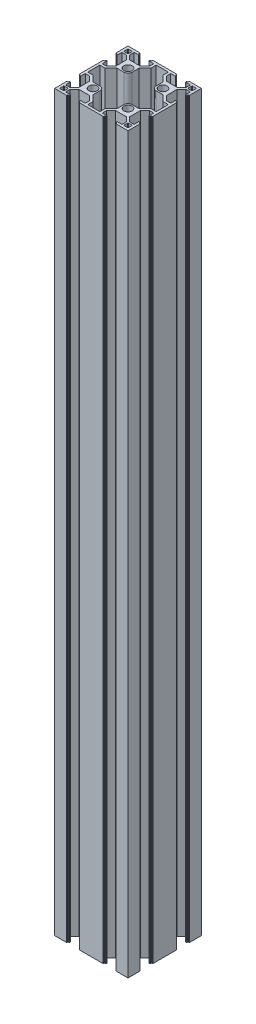
from build123d import *

# Parameters (mm, degrees)
SKETCH1_W                = 60
SKETCH1_H                = 60
BOSS_EXTRUDE1_DEPTH      = 600
CUT_EXTRUDE1_DEPTH       = 602.498129673
CIRPATTERN1_COUNT        = 4
CIRPATTERN1_COPY_1_DEPTH = 602.498129673
CIRPATTERN1_COPY_2_DEPTH = 602.498129673
CIRPATTERN1_COPY_3_DEPTH = 602.498129673
SKETCH4_R                = 3.4
CUT_EXTRUDE2_DEPTH       = 602.498129673
FILLET1_R                = 0.2
FILLET2_R                = 0.2
FILLET3_R                = 0.2
FILLET4_R                = 0.2


with BuildPart() as part:
    # Sketch1 → Boss-Extrude1 (new body)
    with BuildSketch(Plane(origin=(0, 0, 0), x_dir=(1, 0, 0), z_dir=(0, 1, 0))):
        Rectangle(SKETCH1_W, SKETCH1_H)
        Polygon((-23.05, -28), (-6.95, -28), (-6.95, -24.4), (-10.615, -20.8), (-19.385, -20.8), (-23.05, -24.4), align=None, mode=Mode.SUBTRACT)
        Polygon((10.615, -20.8), (19.385, -20.8), (23.05, -24.4), (23.05, -28), (6.95, -28), (6.95, -24.4), align=None, mode=Mode.SUBTRACT)
        Polygon((19.385, 20.8), (23.05, 24.4), (23.05, 28), (6.95, 28), (6.95, 24.4), (10.615, 20.8), align=None, mode=Mode.SUBTRACT)
        Polygon((-23.05, 24.4), (-23.05, 28), (-6.95, 28), (-6.95, 24.4), (-10.615, 20.8), (-19.385, 20.8), align=None, mode=Mode.SUBTRACT)
        Polygon((-20.8, 19.385), (-24.4, 23.05), (-28, 23.05), (-28, 6.95), (-24.4, 6.95), (-20.8, 10.615), align=None, mode=Mode.SUBTRACT)
        Polygon((-24.4, -23.05), (-28, -23.05), (-28, -6.95), (-24.4, -6.95), (-20.8, -10.615), (-20.8, -19.385), align=None, mode=Mode.SUBTRACT)
        Polygon((20.8, -19.385), (24.4, -23.05), (28, -23.05), (28, -6.95), (24.4, -6.95), (20.8, -10.615), align=None, mode=Mode.SUBTRACT)
        Polygon((24.4, 23.05), (28, 23.05), (28, 6.95), (24.4, 6.95), (20.8, 10.615), (20.8, 19.385), align=None, mode=Mode.SUBTRACT)
    extrude(amount=BOSS_EXTRUDE1_DEPTH)

    # Sketch2 → Cut-Extrude1 (cut, through all)
    with BuildSketch(Plane(origin=(0, 600, 0), x_dir=(1, 0, 0), z_dir=(0, 1, 0))):
        Polygon((-19.1, -28), (-19.1, -29), (-20.1, -29), (-20.1, -30), (-9.9, -30), (-9.9, -29), (-10.9, -29), (-10.9, -28), align=None)
    cut_extrude1 = extrude(amount=-CUT_EXTRUDE1_DEPTH, mode=Mode.SUBTRACT)

    # Mirror1: Cut-Extrude1 across plane
    add(cut_extrude1.mirror(Plane(origin=(0, 0, 0), x_dir=(0, 0, 1), z_dir=(1, 0, 0))), mode=Mode.SUBTRACT)

    # CirPattern1: Cut-Extrude1 ×4 about axis
    cirpattern1_axis = Axis((0, 1050, 0), (0, -1, 0))
    for i in range(1, CIRPATTERN1_COUNT):
        add(cut_extrude1.rotate(cirpattern1_axis, i * 360 / CIRPATTERN1_COUNT), mode=Mode.SUBTRACT)

    # CirPattern1 copy 1 sketch → CirPattern1 copy 1 (cut, through all)
    with BuildSketch(Plane(origin=(0, 600, 0), x_dir=(0, 0, -1), z_dir=(0, 1, 0))):
        Polygon((-19.1, 28), (-19.1, 29), (-20.1, 29), (-20.1, 30), (-9.9, 30), (-9.9, 29), (-10.9, 29), (-10.9, 28), align=None)
    extrude(amount=-CIRPATTERN1_COPY_1_DEPTH, mode=Mode.SUBTRACT)

    # CirPattern1 copy 2 sketch → CirPattern1 copy 2 (cut, through all)
    with BuildSketch(Plane(origin=(0, 600, 0), x_dir=(1, 0, 0), z_dir=(0, 1, 0))):
        Polygon((-19.1, 28), (-19.1, 29), (-20.1, 29), (-20.1, 30), (-9.9, 30), (-9.9, 29), (-10.9, 29), (-10.9, 28), align=None)
    extrude(amount=-CIRPATTERN1_COPY_2_DEPTH, mode=Mode.SUBTRACT)

    # CirPattern1 copy 3 sketch → CirPattern1 copy 3 (cut, through all)
    with BuildSketch(Plane.ZX.offset(600)):
        Polygon((-19.1, 28), (-19.1, 29), (-20.1, 29), (-20.1, 30), (-9.9, 30), (-9.9, 29), (-10.9, 29), (-10.9, 28), align=None)
    extrude(amount=-CIRPATTERN1_COPY_3_DEPTH, mode=Mode.SUBTRACT)

    # Sketch4 → Cut-Extrude2 (cut, through all)
    with BuildSketch(Plane(origin=(0, 600, 0), x_dir=(1, 0, 0), z_dir=(0, 1, 0))):
        with BuildLine():
            Line((-13.197035349, 9.797035349), (-18.8, 9.797035349))
            Line((-18.8, 9.797035349), (-23.561071557, 4.95))
            Line((-23.561071557, 4.95), (-28, 4.95))
            Line((-28, 4.95), (-28, -4.95))
            Line((-28, -4.95), (-23.561071557, -4.95))
            Line((-23.561071557, -4.95), (-18.8, -9.797035349))
            Line((-18.8, -9.797035349), (-13.197035349, -9.797035349))
            ThreePointArc((-13.197035349, -9.797035349), (-10.792872293, -10.792872293), (-9.797035349, -13.197035349))
            Line((-9.797035349, -13.197035349), (-9.797035349, -18.8))
            Line((-9.797035349, -18.8), (-4.95, -23.561071557))
            Line((-4.95, -23.561071557), (-4.95, -28))
            Line((-4.95, -28), (4.95, -28))
            Line((4.95, -28), (4.95, -23.561071557))
            Line((4.95, -23.561071557), (9.797035349, -18.8))
            Line((9.797035349, -18.8), (9.797035349, -13.197035349))
            ThreePointArc((9.797035349, -13.197035349), (10.792872293, -10.792872293), (13.197035349, -9.797035349))
            Line((13.197035349, -9.797035349), (18.8, -9.797035349))
            Line((18.8, -9.797035349), (23.561071557, -4.95))
            Line((23.561071557, -4.95), (28, -4.95))
            Line((28, -4.95), (28, 4.95))
            Line((28, 4.95), (23.561071557, 4.95))
            Line((23.561071557, 4.95), (18.8, 9.797035349))
            Line((18.8, 9.797035349), (13.197035349, 9.797035349))
            ThreePointArc((13.197035349, 9.797035349), (10.792872293, 10.792872293), (9.797035349, 13.197035349))
            Line((9.797035349, 13.197035349), (9.797035349, 18.8))
            Line((9.797035349, 18.8), (4.95, 23.561071557))
            Line((4.95, 23.561071557), (4.95, 28))
            Line((4.95, 28), (-4.95, 28))
            Line((-4.95, 28), (-4.95, 23.561071557))
            Line((-4.95, 23.561071557), (-9.797035349, 18.8))
            Line((-9.797035349, 18.8), (-9.797035349, 13.197035349))
            ThreePointArc((-9.797035349, 13.197035349), (-10.792872293, 10.792872293), (-13.197035349, 9.797035349))
        make_face()
        with BuildLine():
            ThreePointArc((-28, -27.5), (-27.853553391, -27.853553391), (-27.5, -28))
            Line((-27.5, -28), (-24.9, -28))
            ThreePointArc((-24.9, -28), (-24.546446609, -27.853553391), (-24.4, -27.5))
            Line((-24.4, -27.5), (-24.4, -24.9))
            ThreePointArc((-24.4, -24.9), (-24.546446609, -24.546446609), (-24.9, -24.4))
            Line((-24.9, -24.4), (-27.5, -24.4))
            ThreePointArc((-27.5, -24.4), (-27.853553391, -24.546446609), (-28, -24.9))
            Line((-28, -24.9), (-28, -27.5))
        make_face()
        with BuildLine():
            ThreePointArc((24.4, -27.5), (24.546446609, -27.853553391), (24.9, -28))
            Line((24.9, -28), (27.5, -28))
            ThreePointArc((27.5, -28), (27.853553391, -27.853553391), (28, -27.5))
            Line((28, -27.5), (28, -24.9))
            ThreePointArc((28, -24.9), (27.853553391, -24.546446609), (27.5, -24.4))
            Line((27.5, -24.4), (24.9, -24.4))
            ThreePointArc((24.9, -24.4), (24.546446609, -24.546446609), (24.4, -24.9))
            Line((24.4, -24.9), (24.4, -27.5))
        make_face()
        with BuildLine():
            ThreePointArc((-27.5, 28), (-27.853553391, 27.853553391), (-28, 27.5))
            Line((-28, 27.5), (-28, 24.9))
            ThreePointArc((-28, 24.9), (-27.853553391, 24.546446609), (-27.5, 24.4))
            Line((-27.5, 24.4), (-24.9, 24.4))
            ThreePointArc((-24.9, 24.4), (-24.546446609, 24.546446609), (-24.4, 24.9))
            Line((-24.4, 24.9), (-24.4, 27.5))
            ThreePointArc((-24.4, 27.5), (-24.546446609, 27.853553391), (-24.9, 28))
            Line((-24.9, 28), (-27.5, 28))
        make_face()
        with BuildLine():
            ThreePointArc((28, 27.5), (27.853553391, 27.853553391), (27.5, 28))
            Line((27.5, 28), (24.9, 28))
            ThreePointArc((24.9, 28), (24.546446609, 27.853553391), (24.4, 27.5))
            Line((24.4, 27.5), (24.4, 24.9))
            ThreePointArc((24.4, 24.9), (24.546446609, 24.546446609), (24.9, 24.4))
            Line((24.9, 24.4), (27.5, 24.4))
            ThreePointArc((27.5, 24.4), (27.853553391, 24.546446609), (28, 24.9))
            Line((28, 24.9), (28, 27.5))
        make_face()
        with Locations((14.298517674, 14.298517674)):
            Circle(SKETCH4_R)
        with Locations((14.298517674, -14.298517674)):
            Circle(SKETCH4_R)
        with Locations((-14.298517674, -14.298517674)):
            Circle(SKETCH4_R)
        with Locations((-14.298517674, 14.298517674)):
            Circle(SKETCH4_R)
    extrude(amount=-CUT_EXTRUDE2_DEPTH, mode=Mode.SUBTRACT)

    # Fillet1
    fillet1_edges = [part.edges().sort_by_distance(p)[0] for p in [
        (28, 300, -19.1),
        (30, 300, -20.1),
        (29, 300, -20.1),
        (29, 300, -19.1),
        (28, 300, 10.9),
        (29, 300, 9.9),
        (28, 300, 19.1),
        (29, 300, 20.1),
        (30, 300, 20.1),
        (29, 300, 19.1),
        (29, 300, 10.9),
        (30, 300, 9.9),
        (30, 300, -9.9),
        (29, 300, -9.9),
        (29, 300, -10.9),
        (28, 300, -10.9),
    ]]
    fillet(fillet1_edges, radius=FILLET1_R)

    # Fillet2
    fillet2_edges = [part.edges().sort_by_distance(p)[0] for p in [
        (-20.1, 0, -29.5),
        (-20.1, 600, -29.5),
        (-20.1, 300, -29),
        (-19.6, 0, -29),
        (-19.1, 300, -29),
        (-19.6, 600, -29),
        (-9.9, 300, -30),
        (-10.9, 300, -28),
        (-10.9, 300, -29),
        (-9.9, 300, -29),
        (19.1, 300, -28),
        (19.1, 300, -29),
        (20.1, 300, -29),
        (20.1, 300, -30),
        (10.9, 300, -28),
        (10.9, 300, -29),
        (9.9, 300, -29),
        (9.9, 300, -30),
        (-19.1, 300, -28),
        (-20.1, 300, -30),
    ]]
    fillet(fillet2_edges, radius=FILLET2_R)

    # Fillet3
    fillet3_edges = [part.edges().sort_by_distance(p)[0] for p in [
        (-29, 300, 9.9),
        (-29, 300, -20.1),
        (-30, 300, -20.1),
        (-29, 300, -19.1),
        (-28, 300, -10.9),
        (-29, 300, -10.9),
        (-29, 300, -9.9),
        (-30, 300, -9.9),
        (-29, 300, 10.9),
        (-30, 300, 9.9),
        (-28, 300, 19.1),
        (-29, 300, 19.1),
        (-29, 300, 20.1),
        (-30, 300, 20.1),
    ]]
    fillet(fillet3_edges, radius=FILLET3_R)

    # Fillet4
    fillet4_edges = [part.edges().sort_by_distance(p)[0] for p in [
        (-19.1, 300, 28),
        (10.9, 300, 28),
        (19.1, 300, 28),
        (20.1, 300, 29),
        (-10.9, 300, 28),
        (-9.9, 300, 29),
        (9.9, 300, 29),
        (-20.1, 300, 29),
        (19.1, 300, 29),
        (20.1, 300, 30),
        (10.9, 300, 29),
        (9.9, 300, 30),
        (-9.9, 300, 30),
        (-10.9, 300, 29),
        (-19.1, 300, 29),
        (-20.1, 300, 30),
    ]]
    fillet(fillet4_edges, radius=FILLET4_R)


solid = part.part
